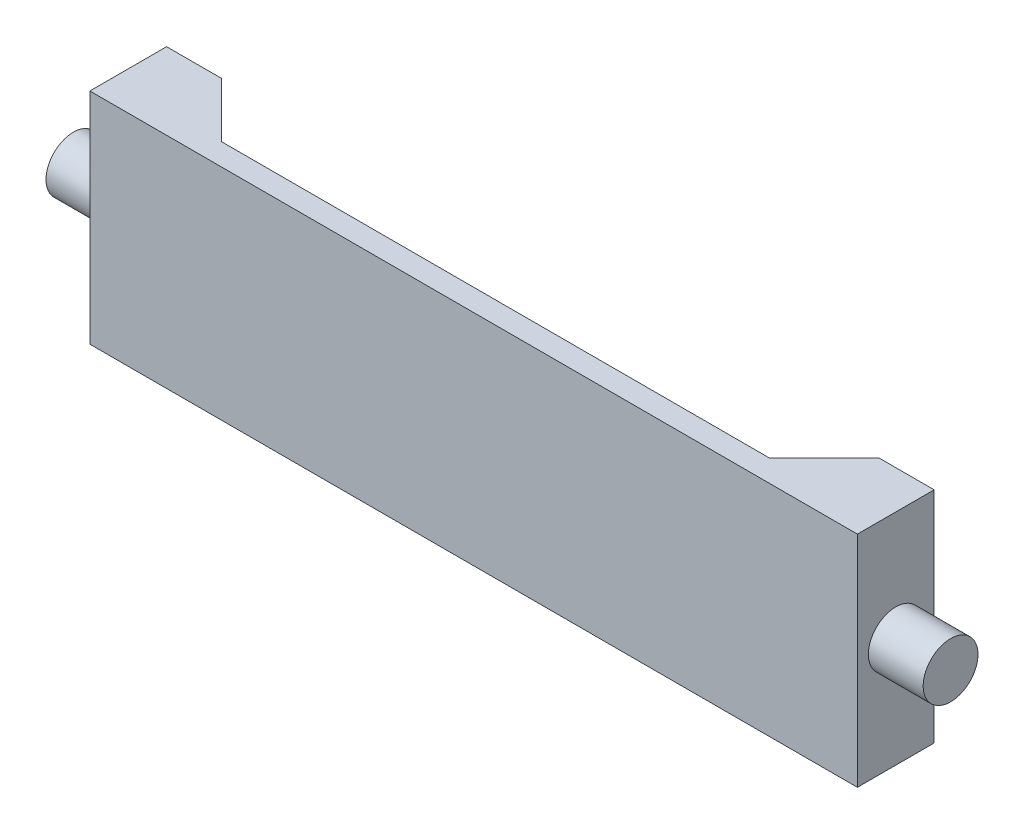
from build123d import *

# Parameters (mm, degrees)
SKETCH1_W           = 700
SKETCH1_H           = 200
BOSS_EXTRUDE1_DEPTH = 70
CUT_EXTRUDE1_DEPTH  = 201
SKETCH3_R           = 25
BOSS_EXTRUDE2_DEPTH = 50
SKETCH4_R           = 25
BOSS_EXTRUDE3_DEPTH = 50


with BuildPart() as part:
    # Sketch1 → Boss-Extrude1 (new body)
    with BuildSketch(Plane.XY):
        Rectangle(SKETCH1_W, SKETCH1_H)
    extrude(amount=BOSS_EXTRUDE1_DEPTH)

    # Sketch2 → Cut-Extrude1 (cut, through all)
    with BuildSketch(Plane.XZ.offset(100)):
        Polygon((-300, 0), (-250, 50), (250, 50), (300, 0), align=None)
    extrude(amount=-CUT_EXTRUDE1_DEPTH, mode=Mode.SUBTRACT)

    # Sketch3 → Boss-Extrude2 (add)
    with BuildSketch(Plane.ZY.offset(350)):
        with Locations((35, 0)):
            Circle(SKETCH3_R)
    extrude(amount=BOSS_EXTRUDE2_DEPTH)

    # Sketch4 → Boss-Extrude3 (add)
    with BuildSketch(Plane(origin=(350, 0, 0), x_dir=(0, 0, -1), z_dir=(1, 0, 0))):
        with Locations((-35, 0)):
            Circle(SKETCH4_R)
    extrude(amount=BOSS_EXTRUDE3_DEPTH)


solid = part.part
